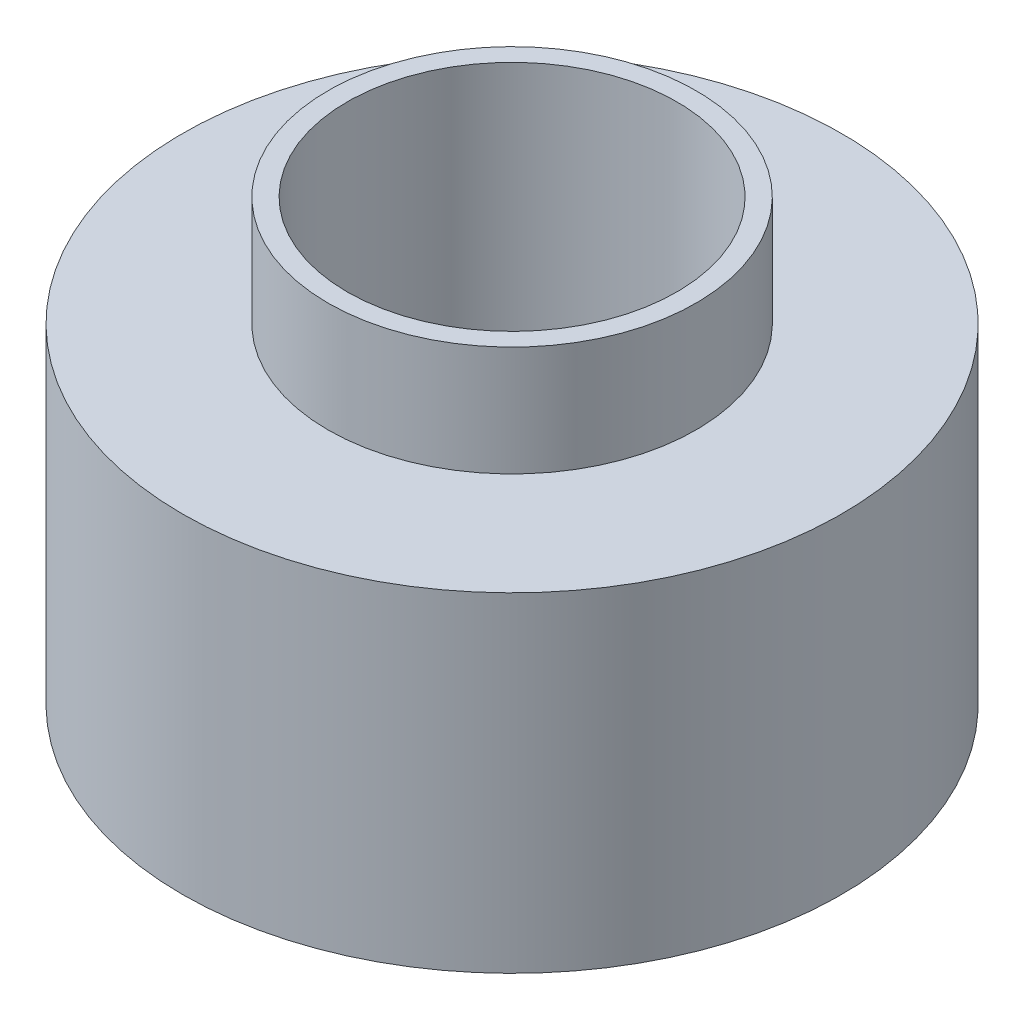
from build123d import *

# Parameters (mm, degrees)
SKETCH2_R               = 4.7625
CUT_EXTRUDE1_DEPTH      = 1
CUT_EXTRUDE1_DEPTH_BACK = 13.7


with BuildPart() as part:
    # Sketch1 → Revolve1 (revolve)
    with BuildSketch(Plane.XY):
        Polygon((0, 12.7), (-5.318497624, 12.7), (-5.318497624, 9.525), (-9.525, 9.525), (-9.525, 0), (0, 0), align=None)
    revolve(axis=Axis((0, 75.791377724, 0), (0, -1, 0)))

    # Sketch2 → Cut-Extrude1 (cut, two sides)
    with BuildSketch(Plane(origin=(0, 12.7, 0), x_dir=(1, 0, 0), z_dir=(0, 1, 0))) as cut_extrude1_sk:
        Circle(SKETCH2_R)
    extrude(amount=CUT_EXTRUDE1_DEPTH, mode=Mode.SUBTRACT)
    extrude(cut_extrude1_sk.sketch, amount=-CUT_EXTRUDE1_DEPTH_BACK, mode=Mode.SUBTRACT)


solid = part.part
